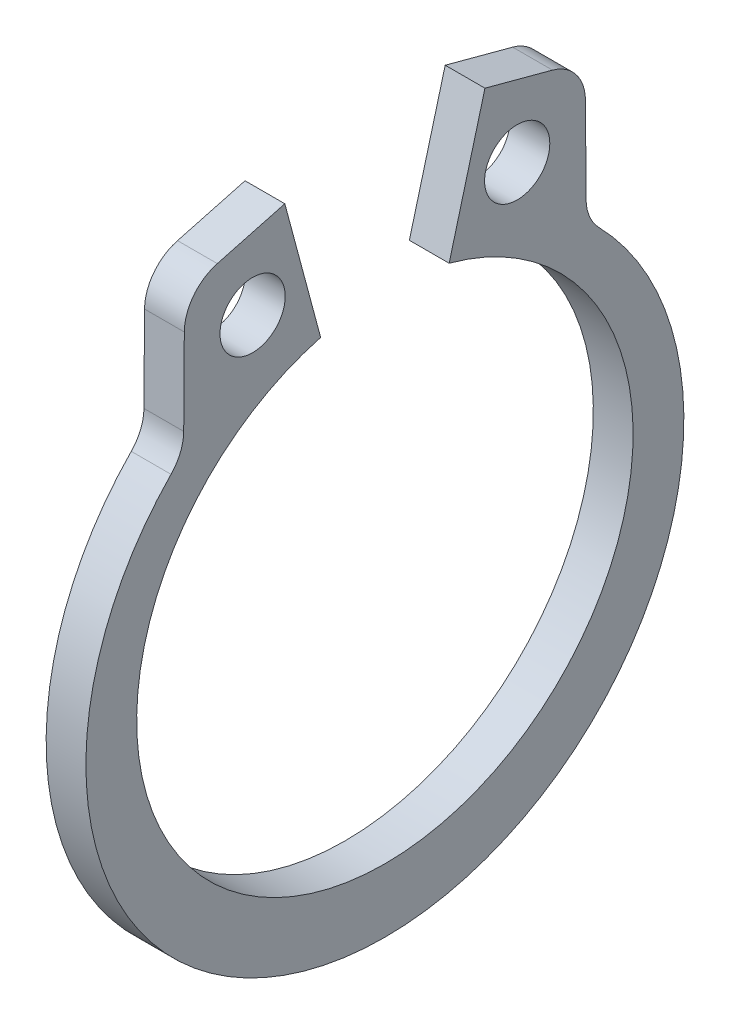
from build123d import *

# Parameters (mm, degrees)
SKETCH1_R      = 0.5207
EXTRUDE1_DEPTH = 0.3175
FILLET1_R      = 0.7112


with BuildPart() as part:
    # Sketch1 → Extrude1 (new body, symmetric)
    with BuildSketch(Plane(origin=(0, 0, 0), x_dir=(0, 0, -1), z_dir=(1, 0, 0))):
        with BuildLine():
            Line((-1.025544584, 3.827384494), (-1.59748291, 5.961887385))
            Line((-1.59748291, 5.961887385), (-3.198360078, 5.532933641))
            Line((-3.198360078, 5.532933641), (-3.213520964, 3.323185649))
            ThreePointArc((-3.213520964, 3.323185649), (0, -4.9784), (3.213520964, 3.323185649))
            Line((3.213520964, 3.323185649), (3.198360078, 5.532933641))
            Line((3.198360078, 5.532933641), (1.59748291, 5.961887385))
            Line((1.59748291, 5.961887385), (1.025544584, 3.827384494))
            ThreePointArc((1.025544584, 3.827384494), (0, -3.9624), (-1.025544584, 3.827384494))
        make_face()
        with Locations((-2.111952331, 4.680159067)):
            Circle(SKETCH1_R, mode=Mode.SUBTRACT)
        with Locations((2.111952331, 4.680159067)):
            Circle(SKETCH1_R, mode=Mode.SUBTRACT)
    extrude(amount=EXTRUDE1_DEPTH, both=True)

    # Fillet1
    fillet1_edges = [part.edges().sort_by_distance(p)[0] for p in [
        (0, 5.532933641, -3.198360078),
        (0, 3.323185649, -3.213520964),
        (0, 3.323185649, 3.213520964),
        (0, 5.532933641, 3.198360078),
    ]]
    fillet(fillet1_edges, radius=FILLET1_R)


solid = part.part
